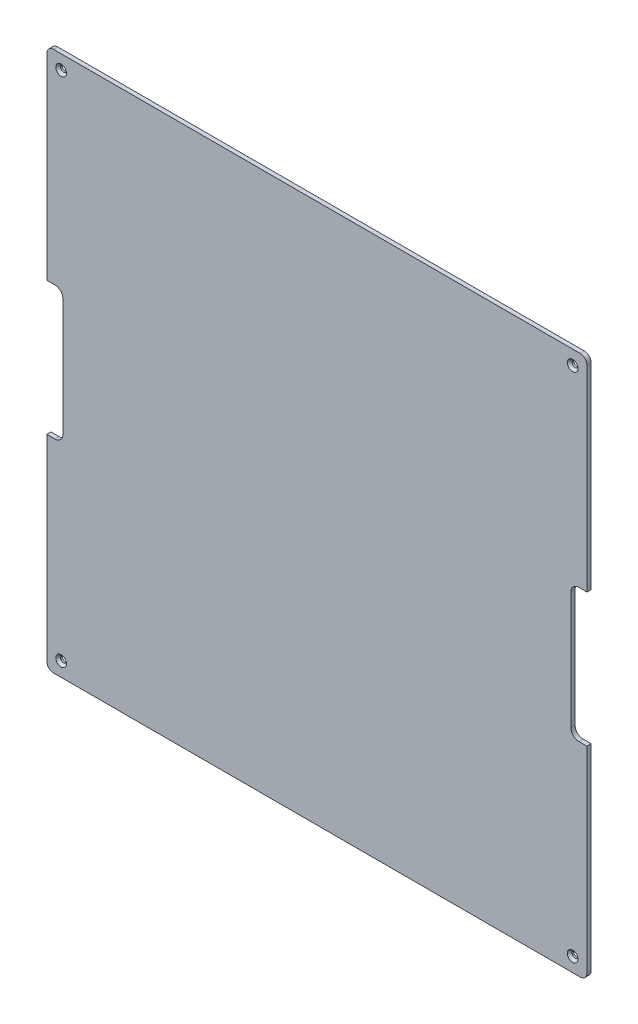
from build123d import *

# Parameters (mm, degrees)
BOSS_EXTRUDE1_DEPTH                            = 1.5748
CSK_FOR_M2_FLAT_HEAD_MACHINE_SCREW1_AT_2_COUNT = 2
CSK_FOR_M2_FLAT_HEAD_MACHINE_SCREW1_AT_2_PITCH = 191.697818903
CSK_FOR_M2_FLAT_HEAD_MACHINE_SCREW1_AT_3_COUNT = 2
CSK_FOR_M2_FLAT_HEAD_MACHINE_SCREW1_AT_3_PITCH = 191.697818903
CSK_FOR_M2_FLAT_HEAD_MACHINE_SCREW1_AT_4_COUNT = 2
CSK_FOR_M2_FLAT_HEAD_MACHINE_SCREW1_AT_4_PITCH = 271.101655369
FILLET1_R                                      = 3
CUT_EXTRUDE1_START                             = -1.5748
CUT_EXTRUDE1_DEPTH                             = 1.5748


with BuildPart() as part:
    # Sketch1 → Boss-Extrude1 (new body)
    with BuildSketch(Plane.XY):
        Polygon((3.302181097, 206.697818903), (3.302181097, 129.997818903), (9.822181097, 129.997818903), (9.822181097, 79.997818903), (3.302181097, 79.997818903), (3.302181097, 3.297818903), (206.702181097, 3.297818903), (206.702181097, 79.997818903), (200.182181097, 79.997818903), (200.182181097, 129.997818903), (206.702181097, 129.997818903), (206.702181097, 206.697818903), align=None)
    extrude(amount=BOSS_EXTRUDE1_DEPTH)

    # Sketch3 → CSK for M2 Flat Head Machine Screw1 (revolve, cut)
    with BuildSketch(Plane(origin=(200.848909451, 9.151090549, 1.5748), x_dir=(0, -1, 0), z_dir=(1, 0, 0))):
        Polygon((0, 0), (0, 1.5748), (1.1, 1.5748), (1.1, 0.9), (2, 0), align=None)
    csk_for_m2_flat_head_machine_screw1 = revolve(axis=Axis((200.848909451, 9.151090549, 7.9248), (0, 0, -1)), mode=Mode.SUBTRACT)

    # CSK for M2 Flat Head Machine Screw1 at 2: CSK for M2 Flat Head Machine Screw1 ×2
    with Locations(*[(-i * CSK_FOR_M2_FLAT_HEAD_MACHINE_SCREW1_AT_2_PITCH, 0, 0) for i in range(1, CSK_FOR_M2_FLAT_HEAD_MACHINE_SCREW1_AT_2_COUNT)]):
        add(csk_for_m2_flat_head_machine_screw1, mode=Mode.SUBTRACT)

    # CSK for M2 Flat Head Machine Screw1 at 3: CSK for M2 Flat Head Machine Screw1 ×2
    with Locations(*[(0, i * CSK_FOR_M2_FLAT_HEAD_MACHINE_SCREW1_AT_3_PITCH, 0) for i in range(1, CSK_FOR_M2_FLAT_HEAD_MACHINE_SCREW1_AT_3_COUNT)]):
        add(csk_for_m2_flat_head_machine_screw1, mode=Mode.SUBTRACT)

    # CSK for M2 Flat Head Machine Screw1 at 4: CSK for M2 Flat Head Machine Screw1 ×2
    with Locations(*[Vector(-0.707106781, 0.707106781, 0) * (i * CSK_FOR_M2_FLAT_HEAD_MACHINE_SCREW1_AT_4_PITCH) for i in range(1, CSK_FOR_M2_FLAT_HEAD_MACHINE_SCREW1_AT_4_COUNT)]):
        add(csk_for_m2_flat_head_machine_screw1, mode=Mode.SUBTRACT)

    # Fillet1
    fillet1_edges = [part.edges().sort_by_distance(p)[0] for p in [
        (206.702181097, 206.697818903, 0.7874),
        (200.182181097, 129.997818903, 0.7874),
        (200.182181097, 79.997818903, 0.7874),
        (206.702181097, 3.297818903, 0.7874),
        (3.302181097, 3.297818903, 0.7874),
        (9.822181097, 79.997818903, 0.7874),
        (9.822181097, 129.997818903, 0.7874),
        (3.302181097, 206.697818903, 0.7874),
    ]]
    fillet(fillet1_edges, radius=FILLET1_R)

    # Sketch4 → Cut-Extrude1 (cut)
    with BuildSketch(Plane.XY.offset(1.5748).offset(CUT_EXTRUDE1_START)):
        with BuildLine():
            Line((6.302181097, 3.297818903), (203.702181097, 3.297818903))
            ThreePointArc((203.702181097, 3.297818903), (205.823501441, 4.176498559), (206.702181097, 6.297818903))
            Line((206.702181097, 6.297818903), (206.702181097, 203.697818903))
            ThreePointArc((206.702181097, 203.697818903), (205.823501441, 205.819139246), (203.702181097, 206.697818903))
            Line((203.702181097, 206.697818903), (6.302181097, 206.697818903))
            ThreePointArc((6.302181097, 206.697818903), (4.180860754, 205.819139246), (3.302181097, 203.697818903))
            Line((3.302181097, 203.697818903), (3.302181097, 6.297818903))
            ThreePointArc((3.302181097, 6.297818903), (4.180860754, 4.176498559), (6.302181097, 3.297818903))
        make_face()
        with BuildLine():
            Line((6.302181097, 3.797818903), (203.702181097, 3.797818903))
            ThreePointArc((203.702181097, 3.797818903), (205.46994805, 4.53005195), (206.202181097, 6.297818903))
            Line((206.202181097, 6.297818903), (206.202181097, 203.697818903))
            ThreePointArc((206.202181097, 203.697818903), (205.46994805, 205.465585856), (203.702181097, 206.197818903))
            Line((203.702181097, 206.197818903), (6.302181097, 206.197818903))
            ThreePointArc((6.302181097, 206.197818903), (4.534414144, 205.465585856), (3.802181097, 203.697818903))
            Line((3.802181097, 203.697818903), (3.802181097, 6.297818903))
            ThreePointArc((3.802181097, 6.297818903), (4.534414144, 4.53005195), (6.302181097, 3.797818903))
        make_face(mode=Mode.SUBTRACT)
    extrude(amount=CUT_EXTRUDE1_DEPTH, mode=Mode.SUBTRACT)


solid = part.part
